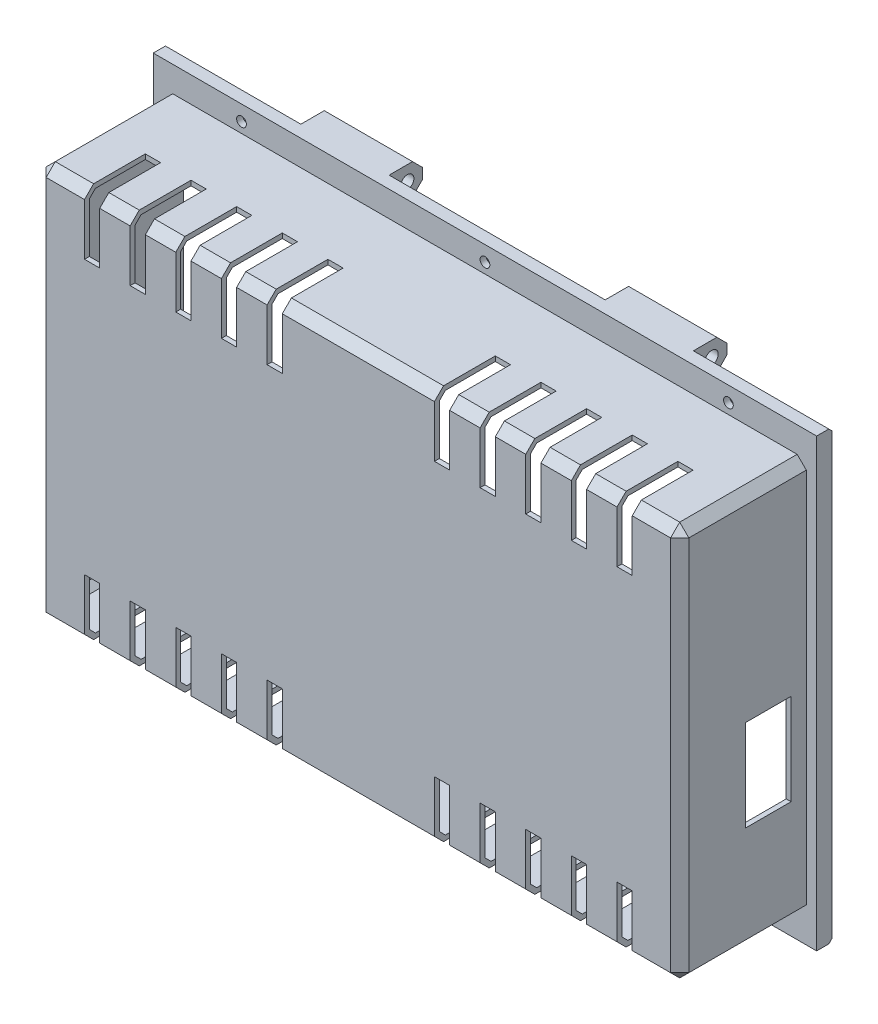
from build123d import *

# Parameters (mm, degrees)
CROQUIS1_W                 = 211.2
CROQUIS1_H                 = 129.74
CROQUIS1_W_2               = 208
CROQUIS1_H_2               = 126.54
SALIENTE_EXTRUIR1_DEPTH    = 40
CROQUIS2_W                 = 218
CROQUIS2_H                 = 146.54
CROQUIS2_W_2               = 208
CROQUIS2_H_2               = 126.54
SALIENTE_EXTRUIR2_DEPTH    = 5
CROQUIS7_R                 = 1.6
CORTAR_EXTRUIR3_DEPTH      = 46
CROQUIS8_R                 = 2.75
CORTAR_EXTRUIR4_DEPTH      = 3
SALIENTE_EXTRUIR3_START    = 35.5
CROQUIS9_R                 = 2.15
SALIENTE_EXTRUIR3_DEPTH    = 29
CHAFL_N3_SIZE              = 3.3
CHAFL_N3_OF_SIMETR_A2_SIZE = 3.3
CHAFL_N2_SIZE              = 1
CROQUIS10_W                = 211.2
CROQUIS10_H                = 129.74
SALIENTE_EXTRUIR4_DEPTH    = 1.6
CHAFL_N4_SIZE              = 2
CHAFL_N5_SIZE              = 3
CORTAR_EXTRUIR5_START      = 30
CROQUIS11_W                = 20
CROQUIS11_H                = 20
CORTAR_EXTRUIR5_DEPTH      = 5
MATRIZL1_COUNT             = 5
MATRIZL1_PITCH             = 15
SIMETR_A3_START            = 30
SIMETR_A3_COPY_1_SKETCH_W  = 20
SIMETR_A3_COPY_1_SKETCH_H  = 20
SIMETR_A3_COPY_1_DEPTH     = 5
SIMETR_A3_COPY_2_SKETCH_W  = 20
SIMETR_A3_COPY_2_SKETCH_H  = 20
SIMETR_A3_COPY_2_DEPTH     = 5
SIMETR_A3_COPY_3_SKETCH_W  = 20
SIMETR_A3_COPY_3_SKETCH_H  = 20
SIMETR_A3_COPY_3_DEPTH     = 5
SIMETR_A3_COPY_4_SKETCH_W  = 20
SIMETR_A3_COPY_4_SKETCH_H  = 20
SIMETR_A3_COPY_4_DEPTH     = 5
SIMETR_A4_START            = 30
SIMETR_A4_COPY_1_SKETCH_W  = 20
SIMETR_A4_COPY_1_SKETCH_H  = 20
SIMETR_A4_COPY_1_DEPTH     = 5
SIMETR_A4_COPY_2_SKETCH_W  = 20
SIMETR_A4_COPY_2_SKETCH_H  = 20
SIMETR_A4_COPY_2_DEPTH     = 5
SIMETR_A4_COPY_3_SKETCH_W  = 20
SIMETR_A4_COPY_3_SKETCH_H  = 20
SIMETR_A4_COPY_3_DEPTH     = 5
SIMETR_A4_COPY_4_SKETCH_W  = 20
SIMETR_A4_COPY_4_SKETCH_H  = 20
SIMETR_A4_COPY_4_DEPTH     = 5
SIMETR_A4_COPY_5_SKETCH_W  = 20
SIMETR_A4_COPY_5_SKETCH_H  = 20
SIMETR_A4_COPY_5_DEPTH     = 5
SIMETR_A4_COPY_6_SKETCH_W  = 20
SIMETR_A4_COPY_6_SKETCH_H  = 20
SIMETR_A4_COPY_6_DEPTH     = 5
SIMETR_A4_COPY_7_SKETCH_W  = 20
SIMETR_A4_COPY_7_SKETCH_H  = 20
SIMETR_A4_COPY_7_DEPTH     = 5
SIMETR_A4_COPY_8_SKETCH_W  = 20
SIMETR_A4_COPY_8_SKETCH_H  = 20
SIMETR_A4_COPY_8_DEPTH     = 5
SIMETR_A4_COPY_9_SKETCH_W  = 20
SIMETR_A4_COPY_9_SKETCH_H  = 20
SIMETR_A4_COPY_9_DEPTH     = 5
CROQUIS12_W                = 15
CROQUIS12_H                = 30
CORTAR_EXTRUIR6_DEPTH      = 215.6


with BuildPart() as part:
    # Croquis1 → Saliente-Extruir1 (new body)
    with BuildSketch(Plane.XY):
        Rectangle(CROQUIS1_W, CROQUIS1_H)
        Rectangle(CROQUIS1_W_2, CROQUIS1_H_2, mode=Mode.SUBTRACT)
    extrude(amount=SALIENTE_EXTRUIR1_DEPTH)

    # Croquis2 → Saliente-Extruir2 (add)
    with BuildSketch(Plane(origin=(0, 0, 0), x_dir=(-1, 0, 0), z_dir=(0, 0, -1))):
        Rectangle(CROQUIS2_W, CROQUIS2_H)
        Rectangle(CROQUIS2_W_2, CROQUIS2_H_2, mode=Mode.SUBTRACT)
    extrude(amount=SALIENTE_EXTRUIR2_DEPTH)

    # Croquis7 → Cortar-Extruir3 (cut, through all)
    with BuildSketch(Plane(origin=(0, 0, -5), x_dir=(-1, 0, 0), z_dir=(0, 0, -1))):
        with Locations((0, 68.27)):
            Circle(CROQUIS7_R)
        with Locations((80, 68.27)):
            Circle(CROQUIS7_R)
        with Locations((-80, 68.27)):
            Circle(CROQUIS7_R)
        with Locations((-80, -68.27)):
            Circle(CROQUIS7_R)
        with Locations((80, -68.27)):
            Circle(CROQUIS7_R)
        with Locations((0, -68.27)):
            Circle(CROQUIS7_R)
    extrude(amount=-CORTAR_EXTRUIR3_DEPTH, mode=Mode.SUBTRACT)

    # Croquis8 → Cortar-Extruir4 (cut)
    with BuildSketch(Plane(origin=(0, 0, -5), x_dir=(-1, 0, 0), z_dir=(0, 0, -1))):
        with Locations((-80, 68.27)):
            Circle(CROQUIS8_R)
        with Locations((0, 68.27)):
            Circle(CROQUIS8_R)
        with Locations((80, 68.27)):
            Circle(CROQUIS8_R)
        with Locations((80, -68.27)):
            Circle(CROQUIS8_R)
        with Locations((0, -68.27)):
            Circle(CROQUIS8_R)
        with Locations((-80, -68.27)):
            Circle(CROQUIS8_R)
    extrude(amount=-CORTAR_EXTRUIR4_DEPTH, mode=Mode.SUBTRACT)

    # Croquis9 → Saliente-Extruir3 (add)
    with BuildSketch(Plane(origin=(0, 0, 0), x_dir=(0, 0, -1), z_dir=(1, 0, 0)).offset(SALIENTE_EXTRUIR3_START)):
        Polygon((5, 73.27), (14.75183495, 73.27), (15, 73.27), (15, 63.27), (5, 63.27), align=None)
        with Locations((10, 68.27)):
            Circle(CROQUIS9_R, mode=Mode.SUBTRACT)
    saliente_extruir3 = extrude(amount=SALIENTE_EXTRUIR3_DEPTH)

    # Chaflán3
    chafl_n3_edges = [part.edges().sort_by_distance(p)[0] for p in [
        (50, 63.27, -15),
        (50, 73.27, -15),
    ]]
    chamfer(chafl_n3_edges, length=CHAFL_N3_SIZE)

    # Simetría2: Saliente-Extruir3 across plane
    add(saliente_extruir3.mirror(Plane(origin=(0, 0, 0), x_dir=(0, 0, 1), z_dir=(1, 0, 0))))

    # Chaflán3 of Simetría2
    chafl_n3_of_simetr_a2_edges = [part.edges().sort_by_distance(p)[0] for p in [
        (-50, 63.27, -15),
        (-50, 73.27, -15),
    ]]
    chamfer(chafl_n3_of_simetr_a2_edges, length=CHAFL_N3_OF_SIMETR_A2_SIZE)

    # Chaflán2
    chafl_n2_edges = [part.edges().sort_by_distance(p)[0] for p in [
        (86.75, 73.27, -5),
        (0, 73.27, -5),
        (-86.75, 73.27, -5),
        (0, -73.27, -5),
    ]]
    chamfer(chafl_n2_edges, length=CHAFL_N2_SIZE)

    # Croquis10 → Saliente-Extruir4 (add)
    with BuildSketch(Plane.XY.offset(40)):
        Rectangle(CROQUIS10_W, CROQUIS10_H)
    extrude(amount=SALIENTE_EXTRUIR4_DEPTH)

    # Chaflán4
    chafl_n4_edges = [part.edges().sort_by_distance(p)[0] for p in [
        (104, -63.27, 17.5),
        (104, 63.27, 17.5),
        (-104, 63.27, 17.5),
        (-104, -63.27, 17.5),
        (104, 0, 40),
        (0, 63.27, 40),
        (-104, 0, 40),
        (0, -63.27, 40),
    ]]
    chamfer(chafl_n4_edges, length=CHAFL_N4_SIZE)

    # Chaflán5
    chafl_n5_edges = [part.edges().sort_by_distance(p)[0] for p in [
        (-105.6, 0, 41.6),
        (0, -64.87, 41.6),
        (105.6, 0, 41.6),
        (0, 64.87, 41.6),
        (105.6, -64.87, 20.8),
        (-105.6, -64.87, 20.8),
        (-105.6, 64.87, 20.8),
        (105.6, 64.87, 20.8),
    ]]
    chamfer(chafl_n5_edges, length=CHAFL_N5_SIZE)

    # Croquis11 → Cortar-Extruir5 (cut)
    with BuildSketch(Plane(origin=(0, 0, 0), x_dir=(0, 0, -1), z_dir=(1, 0, 0)).offset(CORTAR_EXTRUIR5_START)):
        with Locations((-31.6, 54.87)):
            Rectangle(CROQUIS11_W, CROQUIS11_H)
    cortar_extruir5 = extrude(amount=-CORTAR_EXTRUIR5_DEPTH, mode=Mode.SUBTRACT)

    # MatrizL1: Cortar-Extruir5 ×5
    with Locations(*[(i * MATRIZL1_PITCH, 0, 0) for i in range(1, MATRIZL1_COUNT)]):
        add(cortar_extruir5, mode=Mode.SUBTRACT)

    # Simetría3: Cortar-Extruir5 across plane
    add(cortar_extruir5.mirror(Plane(origin=(0, 0, 0), x_dir=(0, 0, 1), z_dir=(1, 0, 0))), mode=Mode.SUBTRACT)

    # Simetría3 copy 1 sketch → Simetría3 copy 1 (cut)
    with BuildSketch(Plane(origin=(-15, 0, 0), x_dir=(0, 0, -1), z_dir=(-1, 0, 0)).offset(SIMETR_A3_START)):
        with Locations((-31.6, -54.87)):
            Rectangle(SIMETR_A3_COPY_1_SKETCH_W, SIMETR_A3_COPY_1_SKETCH_H)
    extrude(amount=-SIMETR_A3_COPY_1_DEPTH, mode=Mode.SUBTRACT)

    # Simetría3 copy 2 sketch → Simetría3 copy 2 (cut)
    with BuildSketch(Plane(origin=(-30, 0, 0), x_dir=(0, 0, -1), z_dir=(-1, 0, 0)).offset(SIMETR_A3_START)):
        with Locations((-31.6, -54.87)):
            Rectangle(SIMETR_A3_COPY_2_SKETCH_W, SIMETR_A3_COPY_2_SKETCH_H)
    extrude(amount=-SIMETR_A3_COPY_2_DEPTH, mode=Mode.SUBTRACT)

    # Simetría3 copy 3 sketch → Simetría3 copy 3 (cut)
    with BuildSketch(Plane(origin=(-45, 0, 0), x_dir=(0, 0, -1), z_dir=(-1, 0, 0)).offset(SIMETR_A3_START)):
        with Locations((-31.6, -54.87)):
            Rectangle(SIMETR_A3_COPY_3_SKETCH_W, SIMETR_A3_COPY_3_SKETCH_H)
    extrude(amount=-SIMETR_A3_COPY_3_DEPTH, mode=Mode.SUBTRACT)

    # Simetría3 copy 4 sketch → Simetría3 copy 4 (cut)
    with BuildSketch(Plane(origin=(-60, 0, 0), x_dir=(0, 0, -1), z_dir=(-1, 0, 0)).offset(SIMETR_A3_START)):
        with Locations((-31.6, -54.87)):
            Rectangle(SIMETR_A3_COPY_4_SKETCH_W, SIMETR_A3_COPY_4_SKETCH_H)
    extrude(amount=-SIMETR_A3_COPY_4_DEPTH, mode=Mode.SUBTRACT)

    # Simetría4: Cortar-Extruir5 across plane
    add(cortar_extruir5.mirror(Plane.ZX), mode=Mode.SUBTRACT)

    # Simetría4 copy 1 sketch → Simetría4 copy 1 (cut)
    with BuildSketch(Plane(origin=(0, 0, 0), x_dir=(0, 0, -1), z_dir=(-1, 0, 0)).offset(SIMETR_A4_START)):
        with Locations((-31.6, 54.87)):
            Rectangle(SIMETR_A4_COPY_1_SKETCH_W, SIMETR_A4_COPY_1_SKETCH_H)
    extrude(amount=-SIMETR_A4_COPY_1_DEPTH, mode=Mode.SUBTRACT)

    # Simetría4 copy 2 sketch → Simetría4 copy 2 (cut)
    with BuildSketch(Plane(origin=(-15, 0, 0), x_dir=(0, 0, -1), z_dir=(-1, 0, 0)).offset(SIMETR_A4_START)):
        with Locations((-31.6, 54.87)):
            Rectangle(SIMETR_A4_COPY_2_SKETCH_W, SIMETR_A4_COPY_2_SKETCH_H)
    extrude(amount=-SIMETR_A4_COPY_2_DEPTH, mode=Mode.SUBTRACT)

    # Simetría4 copy 3 sketch → Simetría4 copy 3 (cut)
    with BuildSketch(Plane(origin=(-30, 0, 0), x_dir=(0, 0, -1), z_dir=(-1, 0, 0)).offset(SIMETR_A4_START)):
        with Locations((-31.6, 54.87)):
            Rectangle(SIMETR_A4_COPY_3_SKETCH_W, SIMETR_A4_COPY_3_SKETCH_H)
    extrude(amount=-SIMETR_A4_COPY_3_DEPTH, mode=Mode.SUBTRACT)

    # Simetría4 copy 4 sketch → Simetría4 copy 4 (cut)
    with BuildSketch(Plane(origin=(-45, 0, 0), x_dir=(0, 0, -1), z_dir=(-1, 0, 0)).offset(SIMETR_A4_START)):
        with Locations((-31.6, 54.87)):
            Rectangle(SIMETR_A4_COPY_4_SKETCH_W, SIMETR_A4_COPY_4_SKETCH_H)
    extrude(amount=-SIMETR_A4_COPY_4_DEPTH, mode=Mode.SUBTRACT)

    # Simetría4 copy 5 sketch → Simetría4 copy 5 (cut)
    with BuildSketch(Plane(origin=(-60, 0, 0), x_dir=(0, 0, -1), z_dir=(-1, 0, 0)).offset(SIMETR_A4_START)):
        with Locations((-31.6, 54.87)):
            Rectangle(SIMETR_A4_COPY_5_SKETCH_W, SIMETR_A4_COPY_5_SKETCH_H)
    extrude(amount=-SIMETR_A4_COPY_5_DEPTH, mode=Mode.SUBTRACT)

    # Simetría4 copy 6 sketch → Simetría4 copy 6 (cut)
    with BuildSketch(Plane(origin=(15, 0, 0), x_dir=(0, 0, -1), z_dir=(1, 0, 0)).offset(SIMETR_A4_START)):
        with Locations((-31.6, -54.87)):
            Rectangle(SIMETR_A4_COPY_6_SKETCH_W, SIMETR_A4_COPY_6_SKETCH_H)
    extrude(amount=-SIMETR_A4_COPY_6_DEPTH, mode=Mode.SUBTRACT)

    # Simetría4 copy 7 sketch → Simetría4 copy 7 (cut)
    with BuildSketch(Plane(origin=(30, 0, 0), x_dir=(0, 0, -1), z_dir=(1, 0, 0)).offset(SIMETR_A4_START)):
        with Locations((-31.6, -54.87)):
            Rectangle(SIMETR_A4_COPY_7_SKETCH_W, SIMETR_A4_COPY_7_SKETCH_H)
    extrude(amount=-SIMETR_A4_COPY_7_DEPTH, mode=Mode.SUBTRACT)

    # Simetría4 copy 8 sketch → Simetría4 copy 8 (cut)
    with BuildSketch(Plane(origin=(45, 0, 0), x_dir=(0, 0, -1), z_dir=(1, 0, 0)).offset(SIMETR_A4_START)):
        with Locations((-31.6, -54.87)):
            Rectangle(SIMETR_A4_COPY_8_SKETCH_W, SIMETR_A4_COPY_8_SKETCH_H)
    extrude(amount=-SIMETR_A4_COPY_8_DEPTH, mode=Mode.SUBTRACT)

    # Simetría4 copy 9 sketch → Simetría4 copy 9 (cut)
    with BuildSketch(Plane(origin=(60, 0, 0), x_dir=(0, 0, -1), z_dir=(1, 0, 0)).offset(SIMETR_A4_START)):
        with Locations((-31.6, -54.87)):
            Rectangle(SIMETR_A4_COPY_9_SKETCH_W, SIMETR_A4_COPY_9_SKETCH_H)
    extrude(amount=-SIMETR_A4_COPY_9_DEPTH, mode=Mode.SUBTRACT)

    # Croquis12 → Cortar-Extruir6 (cut, through all)
    with BuildSketch(Plane.ZY.offset(105.6)):
        with Locations((12.5, -15)):
            Rectangle(CROQUIS12_W, CROQUIS12_H)
    extrude(amount=-CORTAR_EXTRUIR6_DEPTH, mode=Mode.SUBTRACT)


solid = part.part
